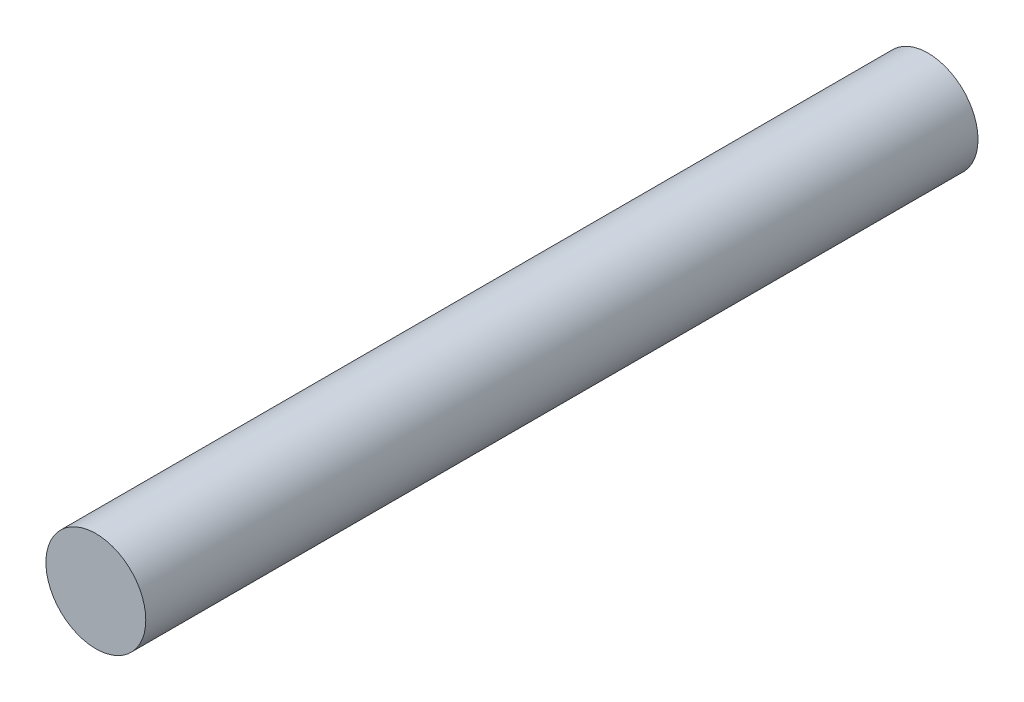
from build123d import *

# Parameters (mm, degrees)
SKETCH1_R           = 1.5
BOSS_EXTRUDE1_DEPTH = 25


with BuildPart() as part:
    # Sketch1 → Boss-Extrude1 (new body)
    with BuildSketch(Plane.XY):
        Circle(SKETCH1_R)
    extrude(amount=-BOSS_EXTRUDE1_DEPTH)


solid = part.part
